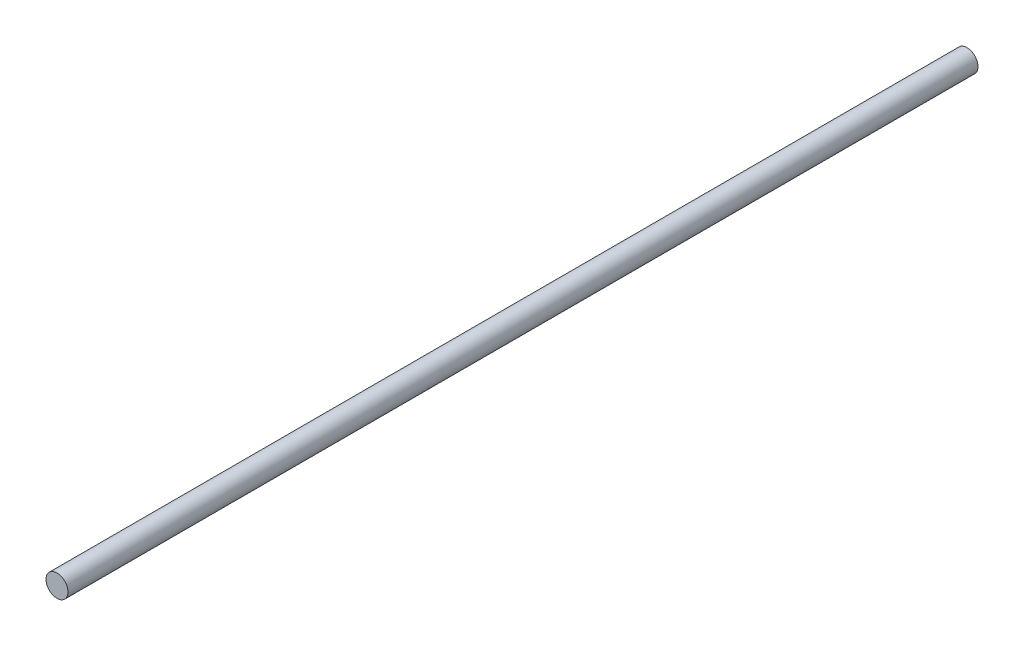
from build123d import *

# Parameters (mm, degrees)
SKETCH1_R           = 0.75
BOSS_EXTRUDE1_DEPTH = 62


with BuildPart() as part:
    # Sketch1 → Boss-Extrude1 (new body)
    with BuildSketch(Plane.XY):
        Circle(SKETCH1_R)
    extrude(amount=BOSS_EXTRUDE1_DEPTH)


solid = part.part
